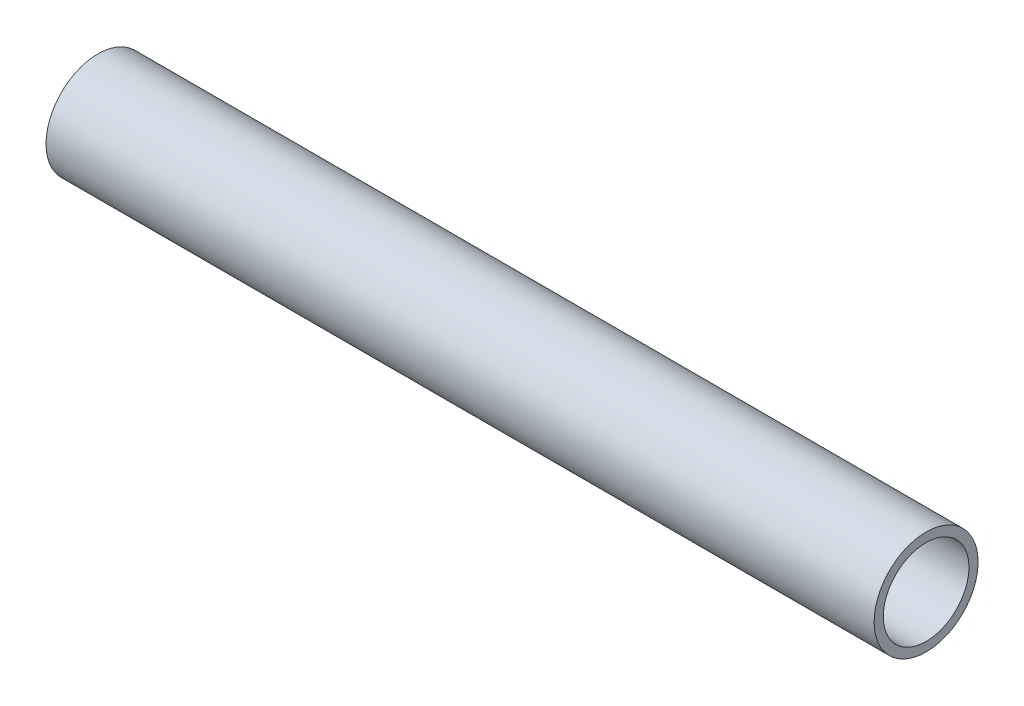
from build123d import *

# Parameters (mm, degrees)
SKETCH1_R               = 3.175
SKETCH1_R_2             = 2.6162
PIPE_0_5_SCH_40_1_DEPTH = 50.571827784


with BuildPart() as part:
    # Sketch1 → Pipe 0.5 SCH 40(1) (new body)
    with BuildSketch(Plane(origin=(-104.128583281, 675.722707309, 0), x_dir=(0, -1, 0), z_dir=(-1, 0, 0))):
        Circle(SKETCH1_R)
        Circle(SKETCH1_R_2, mode=Mode.SUBTRACT)
    extrude(amount=PIPE_0_5_SCH_40_1_DEPTH)


solid = part.part
